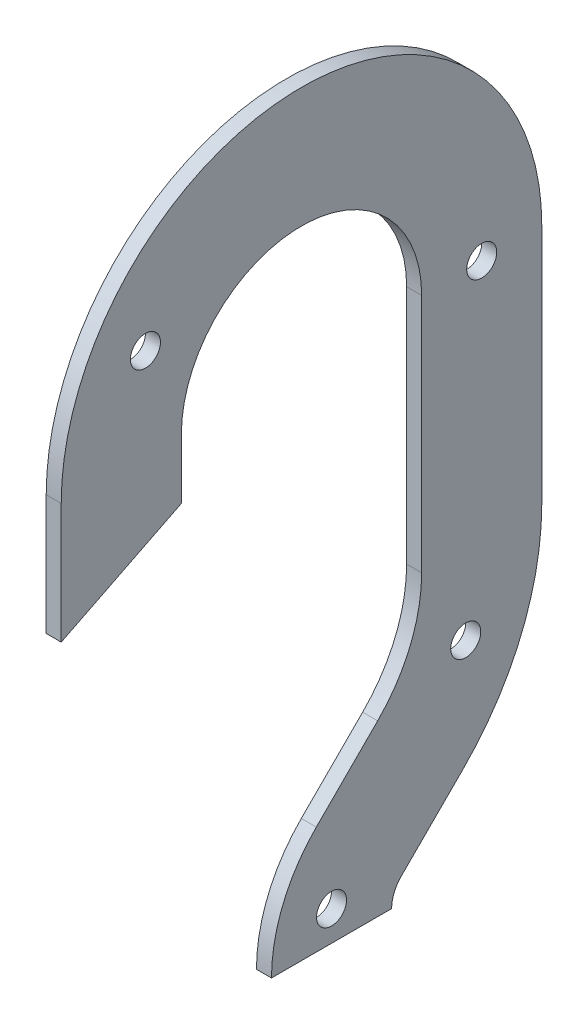
from build123d import *

# Parameters (mm, degrees)
BOSS_EXTRUDE1_DEPTH = 3.175
SKETCH2_R           = 3.175
CUT_EXTRUDE1_DEPTH  = 4.175


with BuildPart() as part:
    # Sketch1 → Boss-Extrude1 (new body)
    with BuildSketch(Plane(origin=(0, 0, 0), x_dir=(0, 0, -1), z_dir=(1, 0, 0))):
        with BuildLine():
            Line((-50.8, 0), (-50.8, -25.4))
            Line((-50.8, -25.4), (-25.4, -12.7))
            Line((-25.4, -12.7), (-25.4, 0))
            ThreePointArc((-25.4, 0), (0, 25.4), (25.4, 0))
            Line((25.4, 0), (25.4, -50.8))
            ThreePointArc((25.4, -50.8), (22.983175157, -62.950198978), (16.100640303, -73.250640303))
            Line((16.100640303, -73.250640303), (3.130634922, -86.220645683))
            ThreePointArc((3.130634922, -86.220645683), (-3.886063261, -96.721876619), (-6.35, -109.108923092))
            Line((-6.35, -109.108923092), (19.05, -109.108923092))
            ThreePointArc((19.05, -109.108923092), (19.580476865, -106.442035801), (21.091147164, -104.181157925))
            Line((21.091147164, -104.181157925), (34.061152545, -91.211152545))
            ThreePointArc((34.061152545, -91.211152545), (46.449715283, -72.67035816), (50.8, -50.8))
            Line((50.8, -50.8), (50.8, 0))
            ThreePointArc((50.8, 0), (0, 50.8), (-50.8, 0))
        make_face()
    extrude(amount=BOSS_EXTRUDE1_DEPTH)

    # Sketch2 → Cut-Extrude1 (cut, through all)
    with BuildSketch(Plane(origin=(3.175, 0, 0), x_dir=(0, 0, -1), z_dir=(1, 0, 0))):
        with Locations((38.1, 0)):
            Circle(SKETCH2_R)
        with Locations((-32.995567884, 19.05)):
            Circle(SKETCH2_R)
        with Locations((34.71644522, -67.810278569)):
            Circle(SKETCH2_R)
        with Locations((6.35, -102.758923092)):
            Circle(SKETCH2_R)
    extrude(amount=-CUT_EXTRUDE1_DEPTH, mode=Mode.SUBTRACT)


solid = part.part
